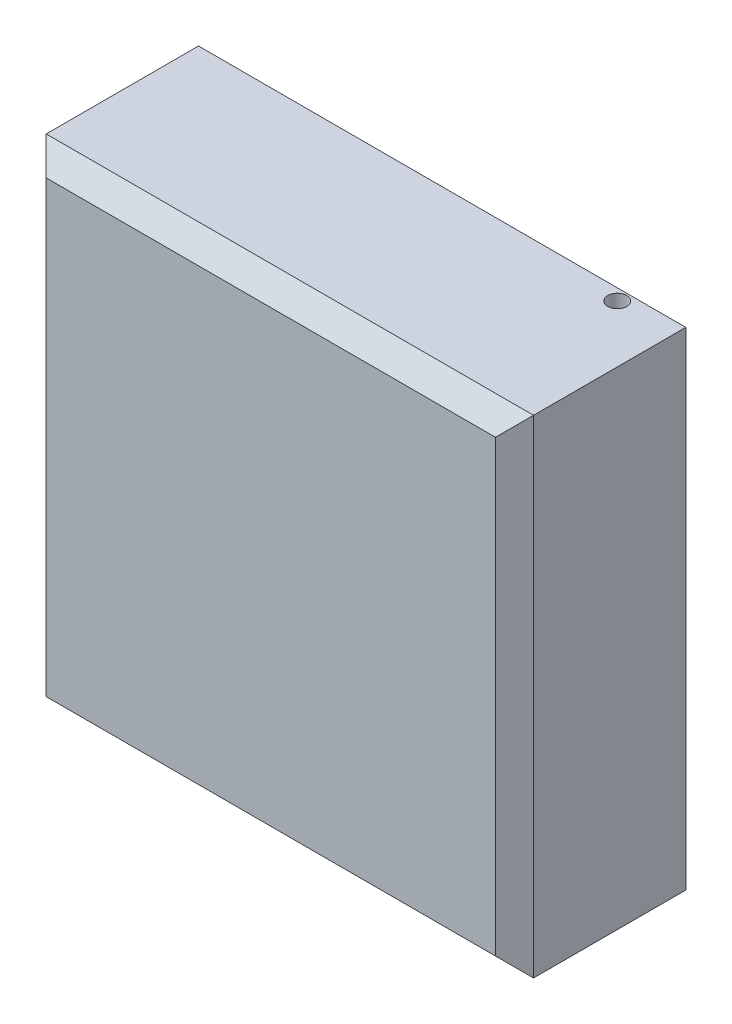
from build123d import *

# Parameters (mm, degrees)
SKETCH_1_W          = 256
SKETCH_1_H          = 256
EXTRUDE_1_DEPTH     = 100
SKETCH_2_R          = 5
CUT_EXTRUDE_1_DEPTH = 257
CHAMFER_1_SIZE      = 10


with BuildPart() as part:
    # 草圖1 → 填料-伸長1 (new body)
    with BuildSketch(Plane.XY):
        Rectangle(SKETCH_1_W, SKETCH_1_H)
    extrude(amount=EXTRUDE_1_DEPTH)

    # 草圖2 → 除料-伸長1 (cut, through all)
    with BuildSketch(Plane.XZ.offset(128)):
        with Locations((98, 16)):
            Circle(SKETCH_2_R)
    extrude(amount=-CUT_EXTRUDE_1_DEPTH, mode=Mode.SUBTRACT)

    # 導角1
    chamfer_1_edges = [part.edges().sort_by_distance(p)[0] for p in [
        (-128, 0, 100),
        (0, -128, 100),
        (128, 0, 100),
        (0, -128, 0),
        (-128, 0, 0),
        (0, 128, 0),
        (128, 0, 0),
        (0, 128, 100),
    ]]
    chamfer(chamfer_1_edges, length=CHAMFER_1_SIZE)


solid = part.part
